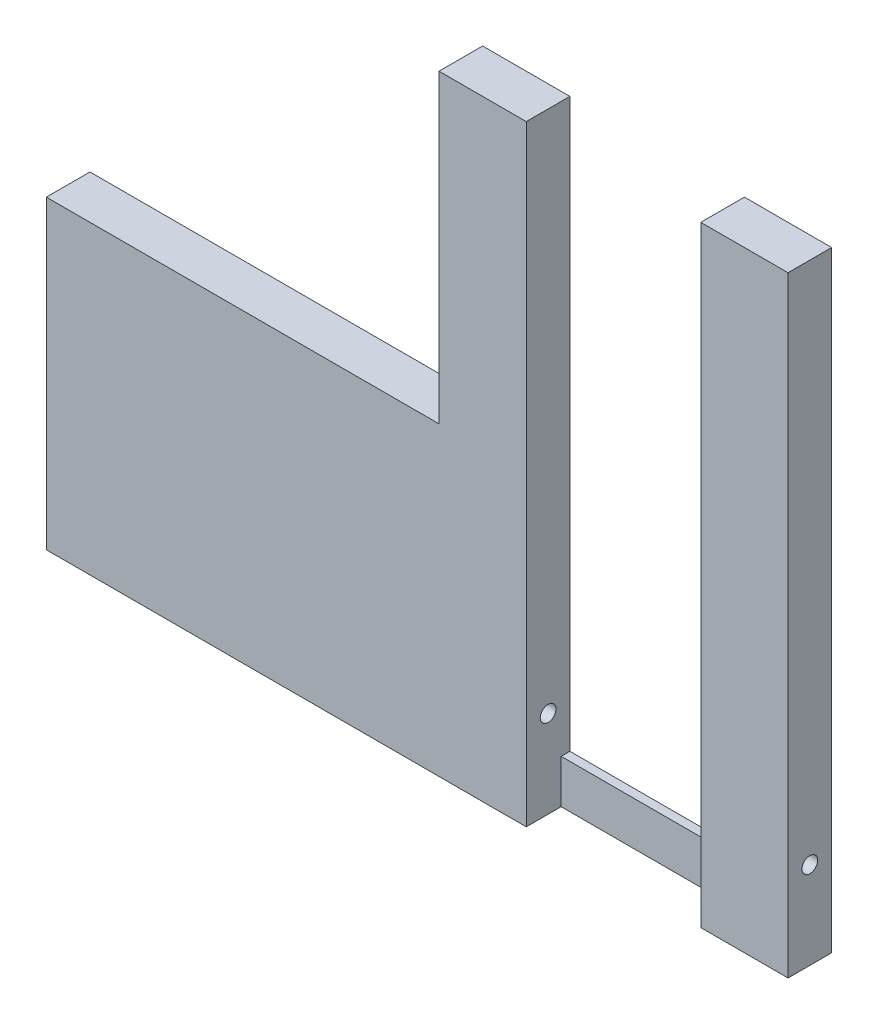
from build123d import *

# Parameters (mm, degrees)
SKETCH2_W             = 4
SKETCH2_H             = 28
BOSS_EXTRUDE1_DEPTH   = 2
BOSS_EXTRUDE1_2_DEPTH = 2
SKETCH3_W             = 16
SKETCH3_H             = 2
BOSS_EXTRUDE2_DEPTH   = 0.4
SKETCH7_W             = 2
SKETCH7_H             = 14
BOSS_EXTRUDE3_DEPTH   = 18
SKETCH6_R             = 0.36
CUT_EXTRUDE1_DEPTH    = 35


with BuildPart() as part:
    # Sketch2 → Boss-Extrude1 (new body)
    with BuildSketch(Plane.XY):
        with Locations((2, 14)):
            Rectangle(SKETCH2_W, SKETCH2_H)
    extrude(amount=BOSS_EXTRUDE1_DEPTH)



with BuildPart() as body_2:
    # Sketch2 → Boss-Extrude1 2 (new body)
    with BuildSketch(Plane.XY):
        with Locations((14, 14)):
            Rectangle(SKETCH2_W, SKETCH2_H)
    extrude(amount=BOSS_EXTRUDE1_2_DEPTH)


with BuildPart() as part_1:
    add(part.part)

    add(body_2.part)  # Boss-Extrude2 merges body 2
    # Sketch3 → Boss-Extrude2 (add)
    with BuildSketch(Plane(origin=(0, 0, 0), x_dir=(-1, 0, 0), z_dir=(0, 0, -1))):
        with Locations((-8, 1)):
            Rectangle(SKETCH3_W, SKETCH3_H)
    extrude(amount=-BOSS_EXTRUDE2_DEPTH)

    # Sketch7 → Boss-Extrude3 (add)
    with BuildSketch(Plane.ZY):
        with Locations((1, 7)):
            Rectangle(SKETCH7_W, SKETCH7_H)
    extrude(amount=BOSS_EXTRUDE3_DEPTH)

    # Sketch6 → Cut-Extrude1 (cut, through all)
    with BuildSketch(Plane(origin=(16, 0, 0), x_dir=(0, 0, -1), z_dir=(1, 0, 0))):
        with Locations((-1, 4)):
            Circle(SKETCH6_R)
    extrude(amount=-CUT_EXTRUDE1_DEPTH, mode=Mode.SUBTRACT)


solid = part_1.part
